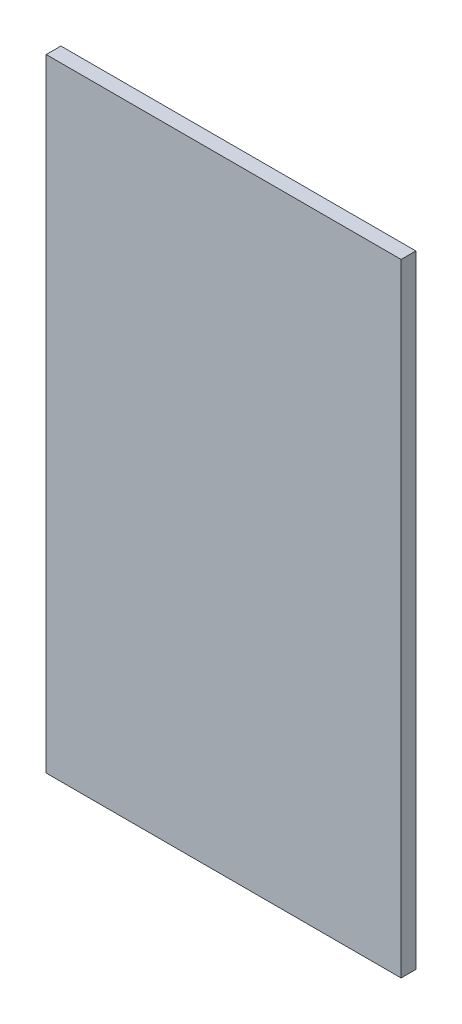
from build123d import *

# Parameters (mm, degrees)
SKETCH1_W           = 433.5
SKETCH1_H           = 760
BOSS_EXTRUDE1_DEPTH = 18


with BuildPart() as part:
    # Sketch1 → Boss-Extrude1 (new body)
    with BuildSketch(Plane.XY):
        Rectangle(SKETCH1_W, SKETCH1_H)
    extrude(amount=BOSS_EXTRUDE1_DEPTH)


solid = part.part
